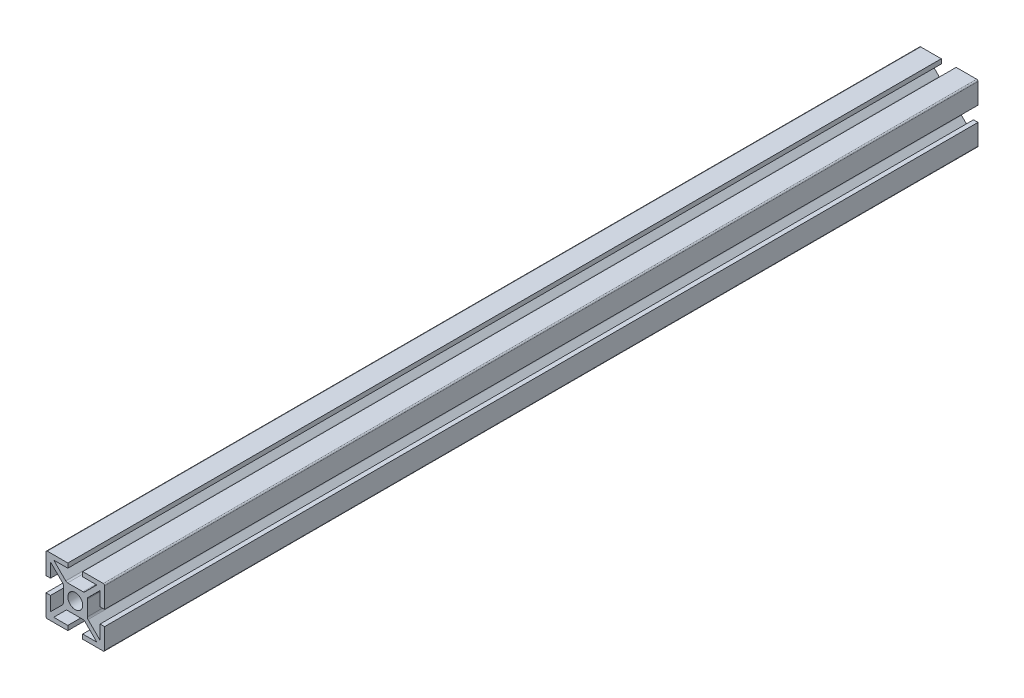
from build123d import *

# Parameters (mm, degrees)
EXTRUSION1_DEPTH        = 328
ESQUISSE2_R             = 2.8
ENL_V_MAT_EXTRU_1_DEPTH = 329
CONG_1_R                = 0.5
CONG_2_R                = 1


with BuildPart() as part:
    # Esquisse1 → Extrusion1 (new body)
    with BuildSketch(Plane.XY):
        Polygon((-2.8, 11), (-2.8, 9.3), (-8.097918472, 9.3), (-3.297918472, 4.5), (3.297918472, 4.5), (8.097918472, 9.3), (2.8, 9.3), (2.8, 11), (11, 11), (11, 2.8), (9.3, 2.8), (9.3, 8.097918472), (4.5, 3.297918472), (4.5, -3.297918472), (9.3, -8.097918472), (9.3, -2.8), (11, -2.8), (11, -11), (2.8, -11), (2.8, -9.3), (8.097918472, -9.3), (3.297918472, -4.5), (-3.297918472, -4.5), (-8.097918472, -9.3), (-2.8, -9.3), (-2.8, -11), (-11, -11), (-11, -2.8), (-9.3, -2.8), (-9.3, -8.097918472), (-4.5, -3.297918472), (-4.5, 3.297918472), (-9.3, 8.097918472), (-9.3, 2.8), (-11, 2.8), (-11, 11), align=None)
    extrude(amount=EXTRUSION1_DEPTH)

    # Esquisse2 → Enlèv. mat.-Extru.1 (cut, through all)
    with BuildSketch(Plane(origin=(0, 0, 0), x_dir=(-1, 0, 0), z_dir=(0, 0, -1))):
        Circle(ESQUISSE2_R)
    extrude(amount=-ENL_V_MAT_EXTRU_1_DEPTH, mode=Mode.SUBTRACT)

    # Congé1
    cong_1_edges = [part.edges().sort_by_distance(p)[0] for p in [
        (-11, 11, 164),
        (11, 11, 164),
        (11, -11, 164),
        (-11, -11, 164),
    ]]
    fillet(cong_1_edges, radius=CONG_1_R)

    # Congé2
    cong_2_edges = [part.edges().sort_by_distance(p)[0] for p in [
        (-4.5, -3.297918472, 164),
        (-4.5, 3.297918472, 164),
        (-3.297918472, 4.5, 164),
        (3.297918472, 4.5, 164),
        (4.5, 3.297918472, 164),
        (4.5, -3.297918472, 164),
        (3.297918472, -4.5, 164),
        (-3.297918472, -4.5, 164),
    ]]
    fillet(cong_2_edges, radius=CONG_2_R)


solid = part.part
